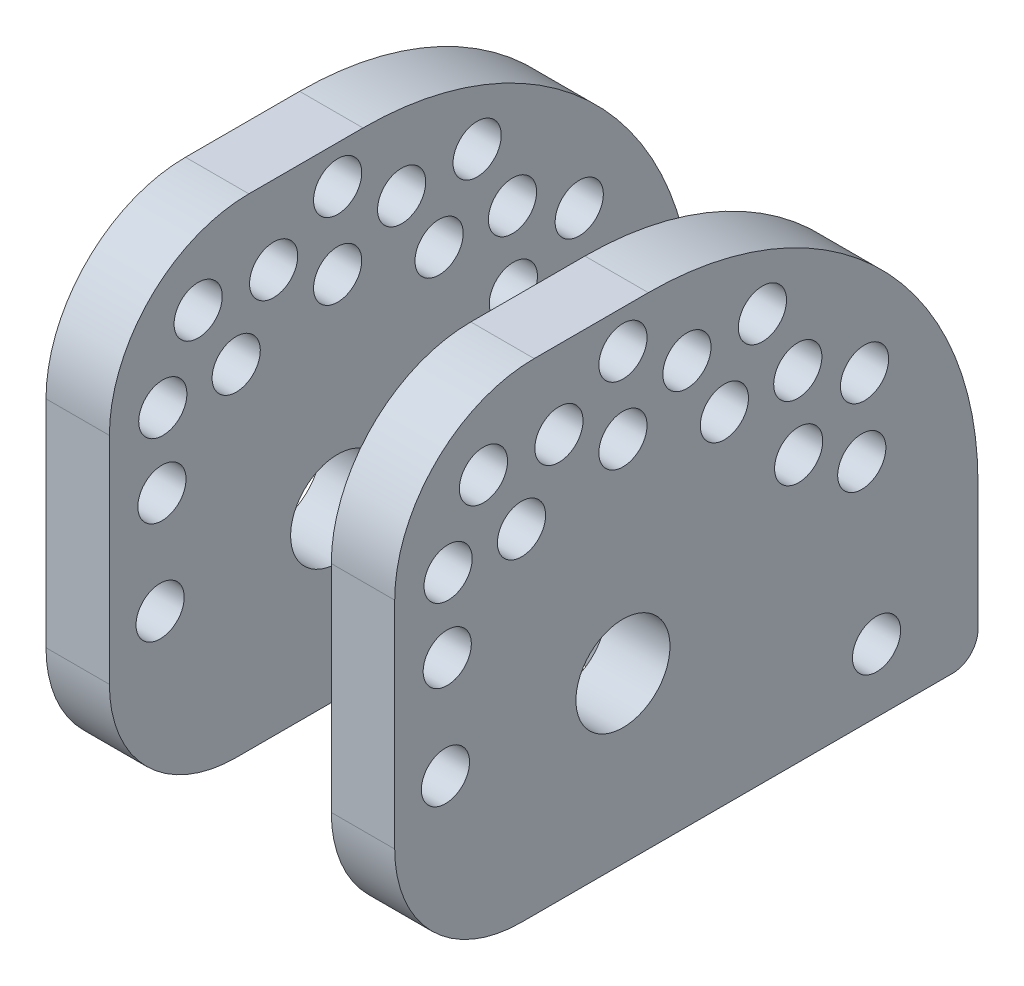
from build123d import *

# Parameters (mm, degrees)
CENTER_MC_BODY_DEPTH           = 9.525
SKETCH2_R                      = 3.9624
CENTER_MC_HOLE_DEPTH           = 9.525
SKETCH3_W                      = 19.05
SKETCH3_H                      = 6.35
SKETCH3_W_2                    = 25.4
CUT_SLOT_DEPTH                 = 9.525
FILLET1_R                      = 12.7
FILLET2_R                      = 12.7
SKETCH12_W                     = 99.695
SKETCH12_H                     = 25.4
CUT_EXTRUDE2_DEPTH             = 10.5250001
BOSS_EXTRUDE1_DEPTH            = 9.525
FILLET3_R                      = 3.175
SKETCH14_W                     = 22.86
SKETCH14_H                     = 27.94
SKETCH14_R                     = 4.7117
BOSS_EXTRUDE2_DEPTH            = 9.525
SKETCH16_W                     = 53.975
SKETCH16_H                     = 15.24
CUT_FOR_THROTTLE_N_BRAKE_DEPTH = 9.525
SKETCH17_W                     = 58.42
SKETCH17_H                     = 48.26
SKETCH17_R                     = 4.7117
BOSS_EXTRUDE3_DEPTH            = 9.525
SKETCH44_W                     = 58.42
SKETCH44_H                     = 48.26
SKETCH44_R                     = 4.7117
BOSS_EXTRUDE4_DEPTH            = 25.4
SKETCH20_R                     = 2.413
CUT_EXTRUDE6_DEPTH             = 35.925
SKETCH21_R                     = 2.413
CUT_EXTRUDE7_DEPTH             = 35.925
CIRPATTERN2_COUNT              = 5
CIRPATTERN2_ANGLE              = 120
SKETCH22_R                     = 2.413
CUT_EXTRUDE10_DEPTH            = 35.925
CIRPATTERN3_COUNT              = 5
CIRPATTERN3_ANGLE              = 120
SKETCH24_R                     = 2.413
CUT_EXTRUDE11_DEPTH            = 35.925
CIRPATTERN4_COUNT              = 4
CIRPATTERN4_ANGLE              = 90
SKETCH48_W                     = 22.225
SKETCH48_H                     = 107.218507126
CUT_EXTRUDE24_DEPTH            = 38.1
SKETCH49_W                     = 22.225
SKETCH49_H                     = 35.56
CUT_EXTRUDE25_DEPTH            = 21.32
FILLET4_R                      = 12.7
FILLET5_R                      = 33.02
FILLET6_R                      = 13.97
SKETCH53_R                     = 2.413
CUT_EXTRUDE29_DEPTH            = 35.925
FILLET7_R                      = 2.54


with BuildPart() as part:
    # Sketch1 → Center MC Body (new body)
    with BuildSketch(Plane(origin=(0, 0, 0), x_dir=(0, 0, -1), z_dir=(1, 0, 0))):
        with BuildLine():
            Line((-12.7, 0), (-12.7, 15.24))
            Line((-12.7, 15.24), (138.43, 15.24))
            Line((138.43, 15.24), (138.43, 16.51))
            ThreePointArc((138.43, 16.51), (147.32, 25.4), (156.21, 16.51))
            Line((156.21, 16.51), (156.21, 0))
            Line((156.21, 0), (-12.7, 0))
        make_face()
    extrude(amount=CENTER_MC_BODY_DEPTH)

    # Sketch2 → Center MC Hole (cut)
    with BuildSketch(Plane(origin=(0, 0, 0), x_dir=(0, 0, -1), z_dir=(1, 0, 0))):
        with Locations((147.32, 16.51)):
            Circle(SKETCH2_R)
    extrude(amount=CENTER_MC_HOLE_DEPTH, mode=Mode.SUBTRACT)

    # Sketch3 → Cut Slot (cut)
    with BuildSketch(Plane(origin=(0, 0, 0), x_dir=(0, 0, -1), z_dir=(1, 0, 0))):
        with Locations((3.175, 12.065)):
            Rectangle(SKETCH3_W, SKETCH3_H)
        with Locations((56.515, 12.065)):
            Rectangle(SKETCH3_W_2, SKETCH3_H)
    extrude(amount=CUT_SLOT_DEPTH, mode=Mode.SUBTRACT)

    # Fillet1
    fillet1_edges = [part.edges().sort_by_distance(p)[0] for p in [
        (4.7625, 0, -156.21),
    ]]
    fillet(fillet1_edges, radius=FILLET1_R)

    # Fillet2
    fillet2_edges = [part.edges().sort_by_distance(p)[0] for p in [
        (4.7625, 15.24, -138.43),
    ]]
    fillet(fillet2_edges, radius=FILLET2_R)

    # Sketch12 → Cut-Extrude2 (cut, through all)
    with BuildSketch(Plane(origin=(0, 0, 0), x_dir=(0, 0, -1), z_dir=(1, 0, 0))):
        with Locations((106.3625, 12.7)):
            Rectangle(SKETCH12_W, SKETCH12_H)
    extrude(amount=CUT_EXTRUDE2_DEPTH, mode=Mode.SUBTRACT)

    # Sketch13 → Boss-Extrude1 (add)
    with BuildSketch(Plane(origin=(0, 0, 0), x_dir=(0, 0, -1), z_dir=(1, 0, 0))):
        Polygon((43.815, 15.24), (50.165, 15.24), (50.165, 8.89), (62.865, 8.89), (62.865, 15.24), (66.675, 15.24), (66.675, 0), (43.815, 0), align=None)
    extrude(amount=BOSS_EXTRUDE1_DEPTH)

    # Fillet3
    fillet3_edges = [part.edges().sort_by_distance(p)[0] for p in [
        (4.7625, 15.24, -66.675),
        (4.7625, 0, -66.675),
    ]]
    fillet(fillet3_edges, radius=FILLET3_R)

    # Sketch14 → Boss-Extrude2 (add)
    with BuildSketch(Plane(origin=(0, 0, 0), x_dir=(0, 0, -1), z_dir=(1, 0, 0))):
        with Locations((-24.13, 13.97)):
            Rectangle(SKETCH14_W, SKETCH14_H)
        with Locations((-22.86, 16.51)):
            Circle(SKETCH14_R, mode=Mode.SUBTRACT)
    extrude(amount=BOSS_EXTRUDE2_DEPTH)

    # Sketch16 → Cut for Throttle n Brake (cut)
    with BuildSketch(Plane(origin=(0, 0, 0), x_dir=(0, 0, -1), z_dir=(1, 0, 0))):
        with Locations((39.6875, 7.62)):
            Rectangle(SKETCH16_W, SKETCH16_H)
    extrude(amount=CUT_FOR_THROTTLE_N_BRAKE_DEPTH, mode=Mode.SUBTRACT)

    # Sketch17 → Boss-Extrude3 (add)
    with BuildSketch(Plane(origin=(0, 0, 0), x_dir=(0, 0, -1), z_dir=(1, 0, 0))):
        with Locations((-16.51, 24.13)):
            Rectangle(SKETCH17_W, SKETCH17_H)
        with Locations((-22.86, 16.51)):
            Circle(SKETCH17_R, mode=Mode.SUBTRACT)
    extrude(amount=BOSS_EXTRUDE3_DEPTH)

    # Sketch44 → Boss-Extrude4 (add)
    with BuildSketch(Plane(origin=(9.525, 0, 0), x_dir=(0, 0, -1), z_dir=(1, 0, 0))):
        with Locations((-16.51, 24.13)):
            Rectangle(SKETCH44_W, SKETCH44_H)
        with Locations((-22.86, 16.51)):
            Circle(SKETCH44_R, mode=Mode.SUBTRACT)
    extrude(amount=BOSS_EXTRUDE4_DEPTH)

    # Sketch20 → Cut-Extrude6 (cut, through all)
    with BuildSketch(Plane(origin=(0, 0, 0), x_dir=(0, 0, -1), z_dir=(1, 0, 0))):
        with Locations((-40.64, 16.51)):
            Circle(SKETCH20_R)
    extrude(amount=CUT_EXTRUDE6_DEPTH, mode=Mode.SUBTRACT)

    # Sketch21 → Cut-Extrude7 (cut, through all)
    with BuildSketch(Plane(origin=(0, 0, 0), x_dir=(0, 0, -1), z_dir=(1, 0, 0))):
        with Locations((-40.457636205, 26.67)):
            Circle(SKETCH21_R)
    cut_extrude7 = extrude(amount=CUT_EXTRUDE7_DEPTH, mode=Mode.SUBTRACT)

    # CirPattern2: Cut-Extrude7 ×5 about axis
    cirpattern2_axis = Axis((0, 16.51, 22.86), (-1, 0, 0))
    for i in range(1, CIRPATTERN2_COUNT):
        add(cut_extrude7.rotate(cirpattern2_axis, i * CIRPATTERN2_ANGLE / (CIRPATTERN2_COUNT - 1)), mode=Mode.SUBTRACT)

    # Sketch22 → Cut-Extrude10 (cut, through all)
    with BuildSketch(Plane(origin=(0, 0, 0), x_dir=(0, 0, -1), z_dir=(1, 0, 0))):
        with Locations((-40.371499436, 34.021499436)):
            Circle(SKETCH22_R)
    cut_extrude10 = extrude(amount=CUT_EXTRUDE10_DEPTH, mode=Mode.SUBTRACT)

    # CirPattern3: Cut-Extrude10 ×5 about axis
    cirpattern3_axis = Axis((0, 16.51, 22.86), (-1, 0, 0))
    for i in range(1, CIRPATTERN3_COUNT):
        add(cut_extrude10.rotate(cirpattern3_axis, i * CIRPATTERN3_ANGLE / (CIRPATTERN3_COUNT - 1)), mode=Mode.SUBTRACT)

    # Sketch24 → Cut-Extrude11 (cut, through all)
    with BuildSketch(Plane(origin=(0, 0, 0), x_dir=(0, 0, -1), z_dir=(1, 0, 0))):
        with Locations((-36.83, 40.706749782)):
            Circle(SKETCH24_R)
    cut_extrude11 = extrude(amount=CUT_EXTRUDE11_DEPTH, mode=Mode.SUBTRACT)

    # CirPattern4: Cut-Extrude11 ×4 about axis
    cirpattern4_axis = Axis((0, 16.51, 22.86), (-1, 0, 0))
    for i in range(1, CIRPATTERN4_COUNT):
        add(cut_extrude11.rotate(cirpattern4_axis, i * CIRPATTERN4_ANGLE / (CIRPATTERN4_COUNT - 1)), mode=Mode.SUBTRACT)

    # Sketch48 → Cut-Extrude24 (cut)
    with BuildSketch(Plane.XY.offset(45.72)):
        with Locations((17.4625, 53.609253563)):
            Rectangle(SKETCH48_W, SKETCH48_H)
    extrude(amount=-CUT_EXTRUDE24_DEPTH, mode=Mode.SUBTRACT)

    # Sketch49 → Cut-Extrude25 (cut, through all)
    with BuildSketch(Plane.XY.offset(7.62)):
        with Locations((17.4625, 30.48)):
            Rectangle(SKETCH49_W, SKETCH49_H)
    extrude(amount=-CUT_EXTRUDE25_DEPTH, mode=Mode.SUBTRACT)

    # Fillet4
    fillet4_edges = [part.edges().sort_by_distance(p)[0] for p in [
        (31.75, 0, 45.72),
        (3.175, 0, 45.72),
    ]]
    fillet(fillet4_edges, radius=FILLET4_R)

    # Fillet5
    fillet5_edges = [part.edges().sort_by_distance(p)[0] for p in [
        (31.75, 48.26, -12.7),
        (3.175, 48.26, -12.7),
    ]]
    fillet(fillet5_edges, radius=FILLET5_R)

    # Fillet6
    fillet6_edges = [part.edges().sort_by_distance(p)[0] for p in [
        (31.75, 48.26, 45.72),
        (3.175, 48.26, 45.72),
    ]]
    fillet(fillet6_edges, radius=FILLET6_R)

    # Sketch53 → Cut-Extrude29 (cut, through all)
    with BuildSketch(Plane(origin=(34.925, 0, 0), x_dir=(0, 0, -1), z_dir=(1, 0, 0))):
        with Locations((2.54, 6.35)):
            Circle(SKETCH53_R)
    extrude(amount=-CUT_EXTRUDE29_DEPTH, mode=Mode.SUBTRACT)

    # Fillet7
    fillet7_edges = [part.edges().sort_by_distance(p)[0] for p in [
        (17.4625, 0, -12.7),
    ]]
    fillet(fillet7_edges, radius=FILLET7_R)


solid = part.part
